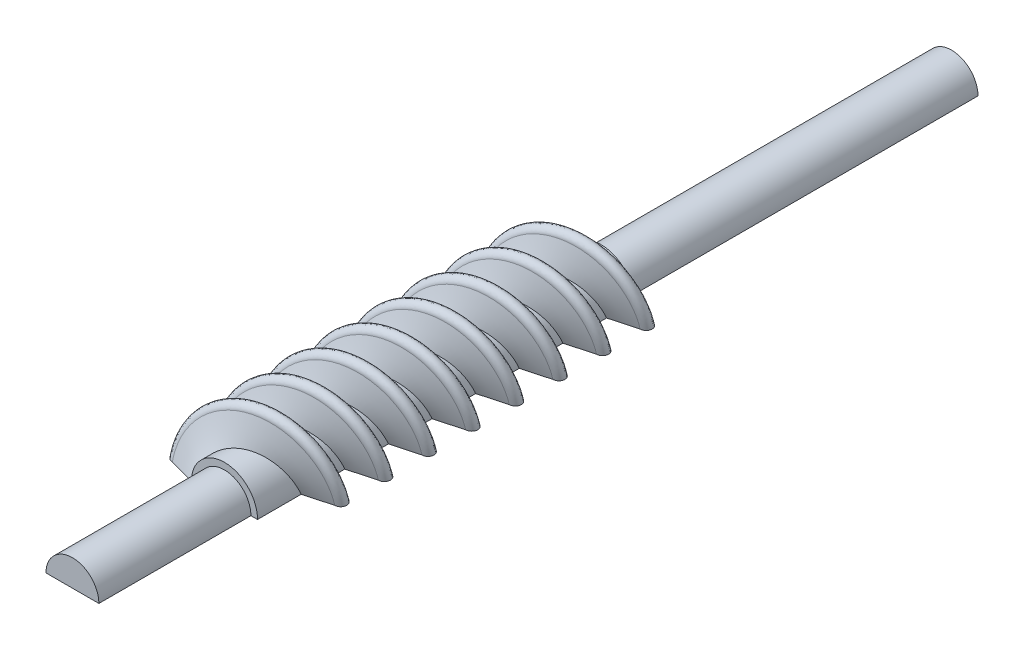
from build123d import *

# Parameters (mm, degrees)
ESQUISSE1_R         = 5
BOSS_EXTRU_1_DEPTH  = 55
BALAYAGE2_PITCH     = 13.2
BALAYAGE2_HEIGHT    = 52.8
BALAYAGE2_RADIUS    = 5
CIRPATTERN1_COUNT   = 2
ARBRE_R             = 4
MOTOR_SIDE_DEPTH    = 53
SKETCH1_R           = 4
BEARING_SIDE_DEPTH  = 25
SKETCH2_R           = 5
BOSS_EXTRUDE2_DEPTH = 2
SKETCH3_W           = 35.88107744
SKETCH3_H           = 11.333129549
CUT_EXTRUDE1_DEPTH  = 134


with BuildPart() as part:
    # Esquisse1 → Boss.-Extru.1 (new body)
    with BuildSketch(Plane.XY):
        Circle(ESQUISSE1_R)
    extrude(amount=BOSS_EXTRU_1_DEPTH)

    # Balayage2: sweep along a helix
    with BuildLine() as balayage2_path:
        Helix(BALAYAGE2_PITCH, BALAYAGE2_HEIGHT, BALAYAGE2_RADIUS, center=(0, 0, 55), direction=(0, 0, -1))
    # Esquisse4 → Balayage2 (sweep)
    with BuildSketch(Plane(origin=(0, 0, 0), x_dir=(1, 0, 0), z_dir=(0, 1, 0))):
        with BuildLine():
            Line((-9, -54.1), (-5, -53))
            Line((-5, -53), (-4.702014603, -53))
            Line((-4.702014603, -53), (-4.702014603, -57))
            Line((-4.702014603, -57), (-5, -57))
            Line((-5, -57), (-9, -55.9))
            ThreePointArc((-9, -55.9), (-9.9, -55), (-9, -54.1))
        make_face()
    balayage2 = sweep(path=balayage2_path.line, is_frenet=True)

    # CirPattern1: Balayage2 ×2 about axis
    cirpattern1_axis = Axis((0, 0, 55), (0, 0, -1))
    for i in range(1, CIRPATTERN1_COUNT):
        add(balayage2.rotate(cirpattern1_axis, i * 360 / CIRPATTERN1_COUNT))

    # Sketch1 → Bearing-side (add)
    with BuildSketch(Plane.XY.offset(55)):
        Circle(SKETCH1_R)
    extrude(amount=BEARING_SIDE_DEPTH)

    # Sketch2 → Boss-Extrude2 (add)
    with BuildSketch(Plane.XY.offset(55)):
        Circle(SKETCH2_R)
    extrude(amount=BOSS_EXTRUDE2_DEPTH)


with BuildPart() as body_2:
    # arbre → Motor-side (new body)
    with BuildSketch(Plane(origin=(0, 0, 0), x_dir=(-1, 0, 0), z_dir=(0, 0, -1))):
        Circle(ARBRE_R)
    extrude(amount=MOTOR_SIDE_DEPTH)


with BuildPart() as cut_extrude1_tool:
    # Sketch3 → Cut-Extrude1 (new body, through all)
    with BuildSketch(Plane.XY.offset(80)):
        with Locations((0.937389423, -5.666564775)):
            Rectangle(SKETCH3_W, SKETCH3_H)
    extrude(amount=-CUT_EXTRUDE1_DEPTH)


with BuildPart() as part_1:
    add(part.part)

    # Cut-Extrude1: cut by cut_extrude1_tool
    add(cut_extrude1_tool.part, mode=Mode.SUBTRACT)


with BuildPart() as body_2_1:
    add(body_2.part)

    # Cut-Extrude1: cut by cut_extrude1_tool
    add(cut_extrude1_tool.part, mode=Mode.SUBTRACT)


solid = Compound([part_1.part, body_2_1.part])
